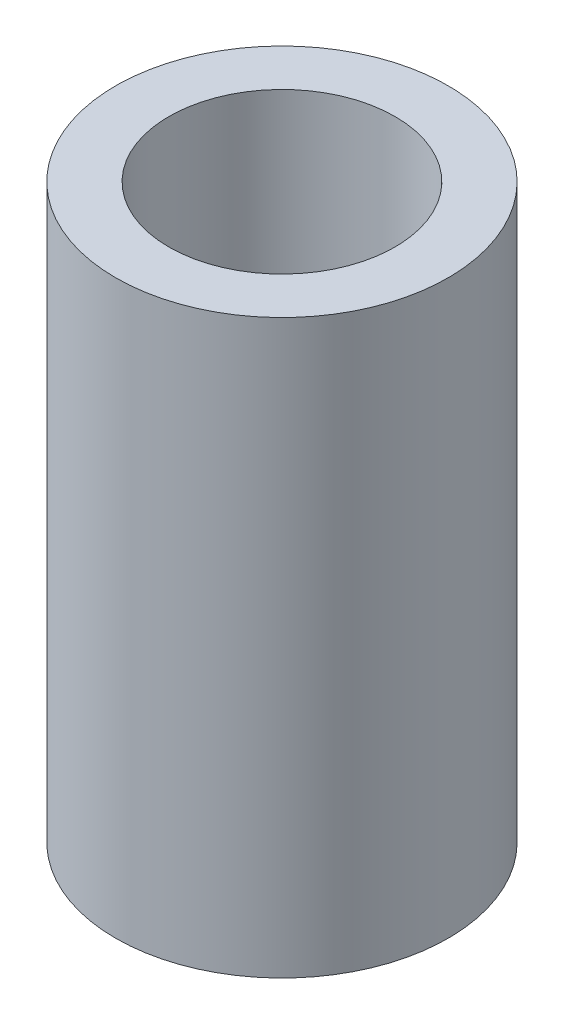
from build123d import *

# Parameters (mm, degrees)
CROQUIS1_R              = 6.25
CROQUIS1_R_2            = 4.25
SALIENTE_EXTRUIR1_DEPTH = 21.5


with BuildPart() as part:
    # Croquis1 → Saliente-Extruir1 (new body)
    with BuildSketch(Plane(origin=(0, 0, 0), x_dir=(1, 0, 0), z_dir=(0, 1, 0))):
        Circle(CROQUIS1_R)
        Circle(CROQUIS1_R_2, mode=Mode.SUBTRACT)
    extrude(amount=SALIENTE_EXTRUIR1_DEPTH)


solid = part.part
